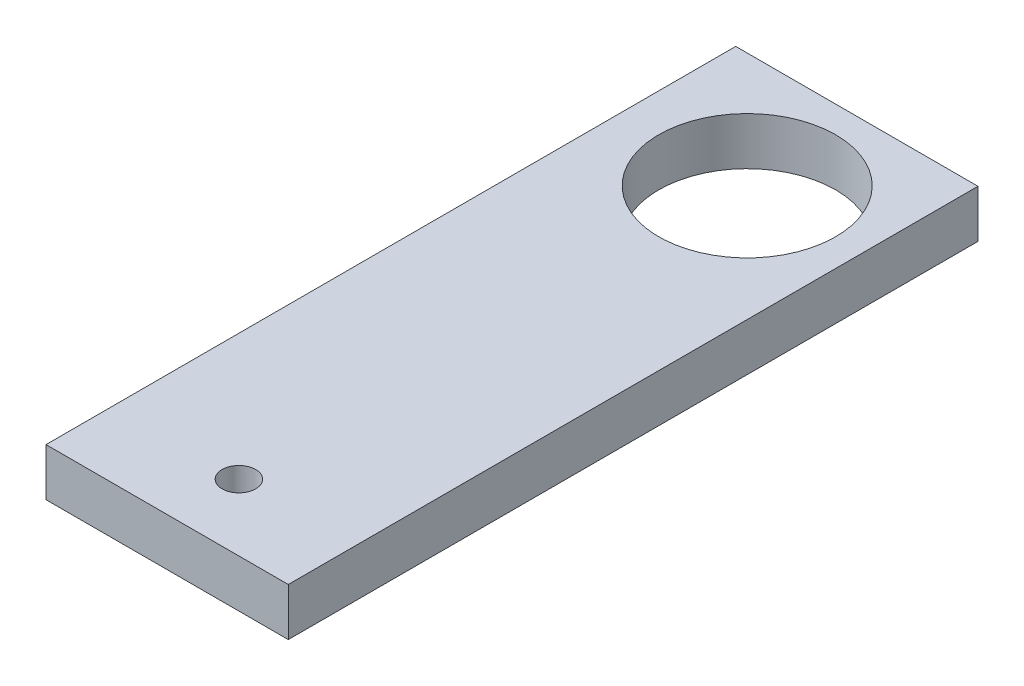
from build123d import *

# Parameters (mm, degrees)
SKETCH1_W           = 6.85
SKETCH1_H           = 19.5
BOSS_EXTRUDE2_DEPTH = 1.35
SKETCH2_R           = 2.5
CUT_EXTRUDE1_DEPTH  = 1.35
SKETCH3_R           = 0.475
CUT_EXTRUDE2_DEPTH  = 1.35


with BuildPart() as part:
    # Sketch1 → Boss-Extrude2 (new body)
    with BuildSketch(Plane(origin=(0, 0, 0), x_dir=(1, 0, 0), z_dir=(0, 1, 0))):
        with Locations((-0.149, 0)):
            Rectangle(SKETCH1_W, SKETCH1_H)
    extrude(amount=BOSS_EXTRUDE2_DEPTH)

    # Sketch2 → Cut-Extrude1 (cut)
    with BuildSketch(Plane.XZ):
        with Locations((0, -6.5)):
            Circle(SKETCH2_R)
    extrude(amount=-CUT_EXTRUDE1_DEPTH, mode=Mode.SUBTRACT)

    # Sketch3 → Cut-Extrude2 (cut)
    with BuildSketch(Plane(origin=(0, 1.35, 0), x_dir=(1, 0, 0), z_dir=(0, 1, 0))):
        with Locations((0, -7.87)):
            Circle(SKETCH3_R)
    extrude(amount=-CUT_EXTRUDE2_DEPTH, mode=Mode.SUBTRACT)


solid = part.part
